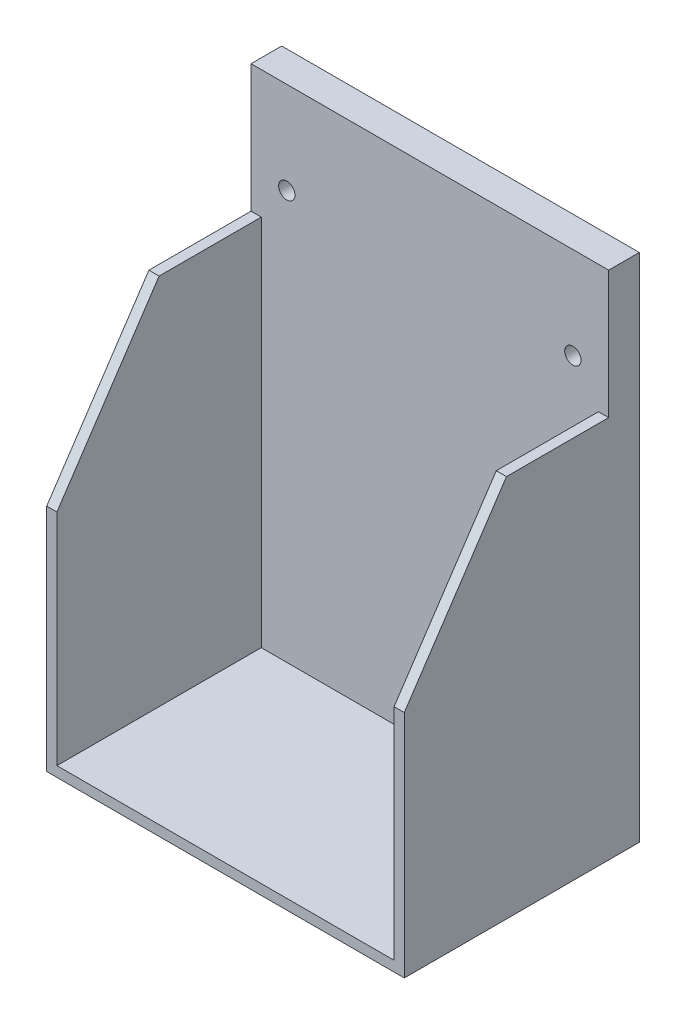
from build123d import *

# Parameters (mm, degrees)
SKETCH_1_W          = 70
SKETCH_1_H          = 100
SKETCH_1_R          = 1.6
EXTRUDE_1_DEPTH     = 6
EXTRUDE_2_DEPTH     = 40
CUT_EXTRUDE_1_DEPTH = 71


with BuildPart() as part:
    # 草图1 → 凸台-拉伸1 (new body)
    with BuildSketch(Plane.XY):
        with Locations((14, -32.141025641)):
            Rectangle(SKETCH_1_W, SKETCH_1_H)
        with Locations((-14, -0.141025641)):
            Circle(SKETCH_1_R, mode=Mode.SUBTRACT)
        with Locations((42, -0.141025641)):
            Circle(SKETCH_1_R, mode=Mode.SUBTRACT)
    extrude(amount=EXTRUDE_1_DEPTH)

    # 草图2 → 凸台-拉伸2 (add)
    with BuildSketch(Plane.XY.offset(6)):
        Polygon((-19, -7.141025641), (-21, -7.141025641), (-21, -80.141025641), (-21, -82.141025641), (-18.055692248, -82.141025641), (46.014859647, -82.141025641), (49, -82.141025641), (49, -79.477981724), (49, -7.141025641), (47, -7.141025641), (47, -80.141025641), (-19, -80.141025641), align=None)
    extrude(amount=EXTRUDE_2_DEPTH)

    # 草图3 → 切除-拉伸1 (cut, through all)
    with BuildSketch(Plane.ZY.offset(21)):
        Polygon((26, -7.141025641), (46, -37.141025641), (46, -7.141025641), align=None)
    extrude(amount=-CUT_EXTRUDE_1_DEPTH, mode=Mode.SUBTRACT)


solid = part.part
